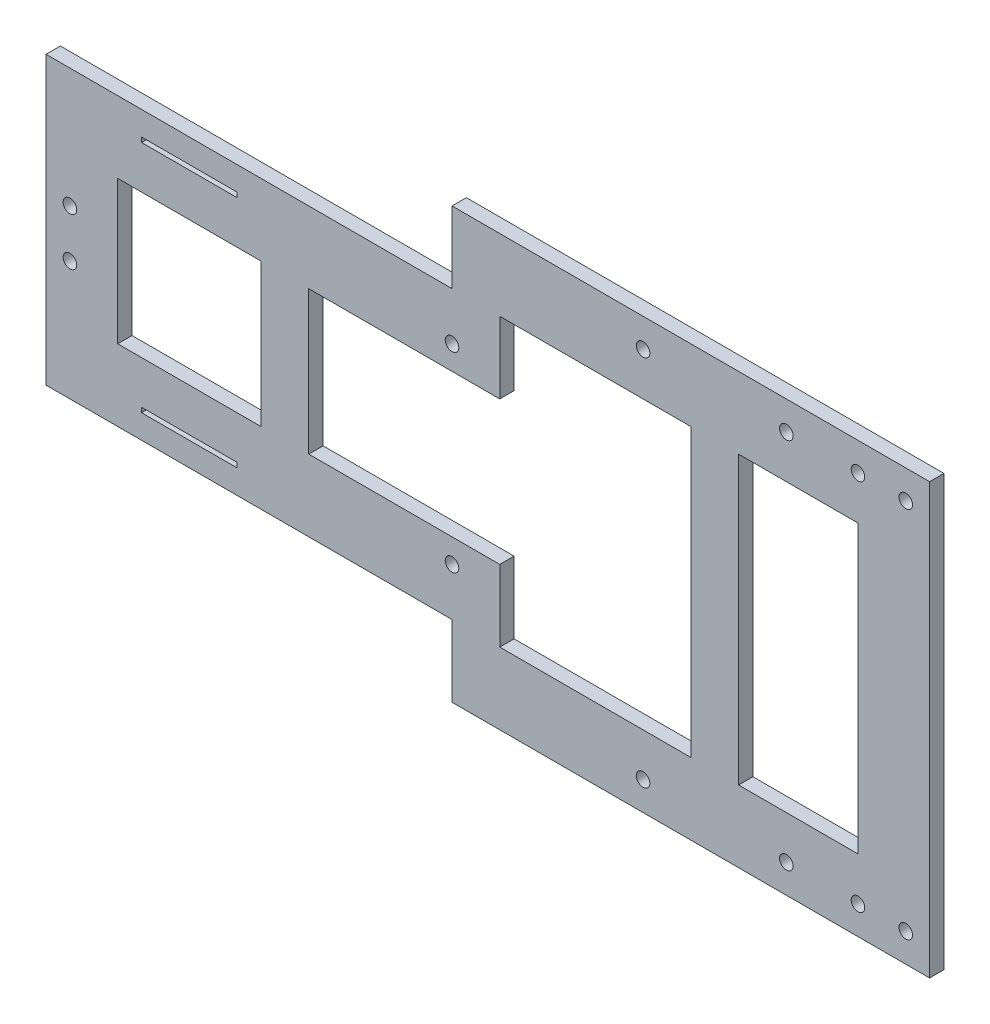
from build123d import *

# Parameters (mm, degrees)
SKETCH1_R           = 1.42
SKETCH1_W           = 25.000092503
SKETCH1_H           = 60
SKETCH1_W_2         = 30
SKETCH1_H_2         = 30
SKETCH1_W_3         = 20
SKETCH1_H_3         = 1
BOSS_EXTRUDE1_DEPTH = 3


with BuildPart() as part:
    # Sketch1 → Boss-Extrude1 (new body)
    with BuildSketch(Plane.XY):
        Polygon((-55, 45), (45, 45), (45, -45), (-55, -45), (-55, -30), (-140, -30), (-140, 30), (-55, 30), align=None)
        with Locations((15, 39)):
            Circle(SKETCH1_R, mode=Mode.SUBTRACT)
        with Locations((-15, 39)):
            Circle(SKETCH1_R, mode=Mode.SUBTRACT)
        with Locations((-15, -39)):
            Circle(SKETCH1_R, mode=Mode.SUBTRACT)
        with Locations((15, -39)):
            Circle(SKETCH1_R, mode=Mode.SUBTRACT)
        with Locations((30.000092503, 39.056338633)):
            Circle(SKETCH1_R, mode=Mode.SUBTRACT)
        with Locations((40, 39.013326424)):
            Circle(SKETCH1_R, mode=Mode.SUBTRACT)
        with Locations((-55, 20)):
            Circle(SKETCH1_R, mode=Mode.SUBTRACT)
        with Locations((-55, -20)):
            Circle(SKETCH1_R, mode=Mode.SUBTRACT)
        with Locations((40, -39.013326424)):
            Circle(SKETCH1_R, mode=Mode.SUBTRACT)
        with Locations((30.000092503, -39.056338633)):
            Circle(SKETCH1_R, mode=Mode.SUBTRACT)
        with Locations((-135, 5)):
            Circle(SKETCH1_R, mode=Mode.SUBTRACT)
        with Locations((-135, -5)):
            Circle(SKETCH1_R, mode=Mode.SUBTRACT)
        Polygon((-15, 30), (-45, 30), (-45, 15), (-85, 15), (-85, -15), (-45, -15), (-45, -30), (-5, -30), (-5, 30), align=None, mode=Mode.SUBTRACT)
        with Locations((17.500046252, 0)):
            Rectangle(SKETCH1_W, SKETCH1_H, mode=Mode.SUBTRACT)
        with Locations((-110, 0)):
            Rectangle(SKETCH1_W_2, SKETCH1_H_2, mode=Mode.SUBTRACT)
        with Locations((-110, -24.5)):
            Rectangle(SKETCH1_W_3, SKETCH1_H_3, mode=Mode.SUBTRACT)
        with Locations((-110, 24.5)):
            Rectangle(SKETCH1_W_3, SKETCH1_H_3, mode=Mode.SUBTRACT)
    extrude(amount=BOSS_EXTRUDE1_DEPTH)


solid = part.part
